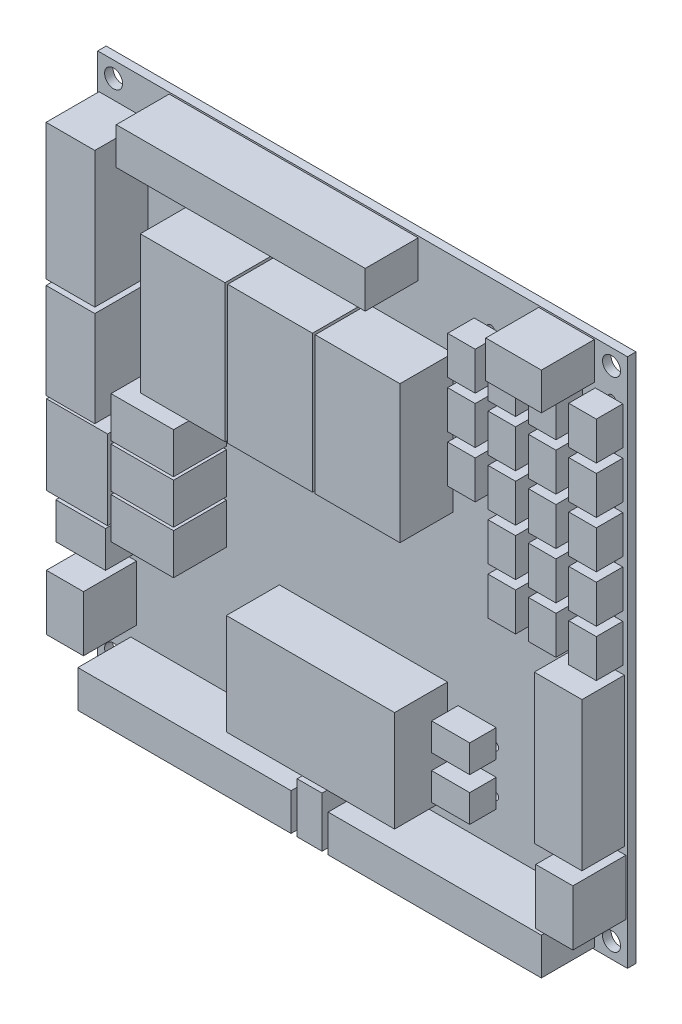
from build123d import *

# Parameters (mm, degrees)
ESQUISSE1_W        = 100.0000032
ESQUISSE1_H        = 100.0000032
ESQUISSE1_R        = 1.6999966
ESQUISSE1_R_2      = 1.1999976
ESQUISSE1_R_3      = 0.7500112
ESQUISSE1_R_4      = 0.4500118
BOSS_EXTRU_1_DEPTH = 1.6
ESQUISSE3_W        = 9.200007
ESQUISSE3_H        = 25.6200148
ESQUISSE3_H_2      = 18.0000148
ESQUISSE3_W_2      = 11.5000024
ESQUISSE3_H_3      = 14.9999954
ESQUISSE3_W_3      = 16.0000188
ESQUISSE3_H_4      = 25.9999988
ESQUISSE3_W_4      = 31.75
ESQUISSE3_H_5      = 19.05
ESQUISSE3_W_5      = 11.7999764
ESQUISSE3_H_6      = 7.6999846
BOSS_EXTRU_2_DEPTH = 10
ESQUISSE4_W        = 47.0000076
ESQUISSE4_H        = 6.999986
ESQUISSE4_W_2      = 10.5000044
ESQUISSE4_W_3      = 40.2500084
ESQUISSE4_W_4      = 6.999986
ESQUISSE4_H_2      = 10.5000044
ESQUISSE4_W_5      = 4.700016
ESQUISSE4_H_3      = 9.5000064
BOSS_EXTRU_3_DEPTH = 10
ESQUISSE5_W        = 5.1999896
ESQUISSE5_H        = 7.1999856
ESQUISSE5_W_2      = 7.1999856
ESQUISSE5_H_2      = 5.1999896
BOSS_EXTRU_4_DEPTH = 5
ESQUISSE6_W        = 9.3962982
ESQUISSE6_H        = 6.8525136
ESQUISSE6_W_2      = 8.999982
ESQUISSE6_H_2      = 27.9999948
BOSS_EXTRU_5_DEPTH = 8


with BuildPart() as part:
    # Esquisse1 → Boss.-Extru.1 (new body)
    with BuildSketch(Plane.XY):
        with Locations((50.0508016, 50.0508016)):
            Rectangle(ESQUISSE1_W, ESQUISSE1_H)
        with Locations((3.050794, 97.0508092)):
            Circle(ESQUISSE1_R, mode=Mode.SUBTRACT)
        with Locations((97.0508092, 97.0508092)):
            Circle(ESQUISSE1_R, mode=Mode.SUBTRACT)
        with Locations((97.0508092, 3.050794)):
            Circle(ESQUISSE1_R, mode=Mode.SUBTRACT)
        with Locations((3.050794, 3.050794)):
            Circle(ESQUISSE1_R, mode=Mode.SUBTRACT)
        with Locations((7.4058018, 64.0407914)):
            Circle(ESQUISSE1_R_2, mode=Mode.SUBTRACT)
        with Locations((7.4058018, 51.6308086)):
            Circle(ESQUISSE1_R_2, mode=Mode.SUBTRACT)
        with Locations((74.9837972, 23.9048036)):
            Circle(ESQUISSE1_R_3, mode=Mode.SUBTRACT)
        with Locations((74.9837972, 15.7768036)):
            Circle(ESQUISSE1_R_3, mode=Mode.SUBTRACT)
        with Locations((81.8607964, 91.6207972)):
            Circle(ESQUISSE1_R_3, mode=Mode.SUBTRACT)
        with Locations((81.8607964, 82.7307972)):
            Circle(ESQUISSE1_R_3, mode=Mode.SUBTRACT)
        with Locations((81.8607964, 73.8407972)):
            Circle(ESQUISSE1_R_3, mode=Mode.SUBTRACT)
        with Locations((81.8607964, 64.9507972)):
            Circle(ESQUISSE1_R_3, mode=Mode.SUBTRACT)
        with Locations((81.8607964, 56.0607972)):
            Circle(ESQUISSE1_R_3, mode=Mode.SUBTRACT)
        with Locations((74.2407964, 91.6207972)):
            Circle(ESQUISSE1_R_3, mode=Mode.SUBTRACT)
        with Locations((74.2407964, 82.7307972)):
            Circle(ESQUISSE1_R_3, mode=Mode.SUBTRACT)
        with Locations((74.2407964, 73.8407972)):
            Circle(ESQUISSE1_R_3, mode=Mode.SUBTRACT)
        with Locations((97.1007964, 91.6207972)):
            Circle(ESQUISSE1_R_3, mode=Mode.SUBTRACT)
        with Locations((97.1007964, 82.7307972)):
            Circle(ESQUISSE1_R_3, mode=Mode.SUBTRACT)
        with Locations((97.1007964, 73.8407972)):
            Circle(ESQUISSE1_R_3, mode=Mode.SUBTRACT)
        with Locations((97.1007964, 64.9507972)):
            Circle(ESQUISSE1_R_3, mode=Mode.SUBTRACT)
        with Locations((97.1007964, 56.0607972)):
            Circle(ESQUISSE1_R_3, mode=Mode.SUBTRACT)
        with Locations((89.4807964, 91.6207972)):
            Circle(ESQUISSE1_R_3, mode=Mode.SUBTRACT)
        with Locations((89.4807964, 82.7307972)):
            Circle(ESQUISSE1_R_3, mode=Mode.SUBTRACT)
        with Locations((89.4807964, 73.8407972)):
            Circle(ESQUISSE1_R_3, mode=Mode.SUBTRACT)
        with Locations((89.4807964, 64.9507972)):
            Circle(ESQUISSE1_R_3, mode=Mode.SUBTRACT)
        with Locations((89.4807964, 56.0607972)):
            Circle(ESQUISSE1_R_3, mode=Mode.SUBTRACT)
        with Locations((7.4058018, 90.7107914)):
            Circle(ESQUISSE1_R_2, mode=Mode.SUBTRACT)
        with Locations((7.4058018, 70.6808086)):
            Circle(ESQUISSE1_R_2, mode=Mode.SUBTRACT)
        with Locations((6.0527946, 29.0658042)):
            Circle(ESQUISSE1_R_4, mode=Mode.SUBTRACT)
        with Locations((6.0527946, 24.6657876)):
            Circle(ESQUISSE1_R_4, mode=Mode.SUBTRACT)
    extrude(amount=BOSS_EXTRU_1_DEPTH)

    # Esquisse3 → Boss.-Extru.2 (add)
    with BuildSketch(Plane.XY.offset(1.6)):
        with Locations((4.9057941, 80.6958)):
            Rectangle(ESQUISSE3_W, ESQUISSE3_H)
        with Locations((4.9057941, 57.8358)):
            Rectangle(ESQUISSE3_W, ESQUISSE3_H_2)
        with Locations((6.1557916, 40.8508073)):
            Rectangle(ESQUISSE3_W_2, ESQUISSE3_H_3)
        with Locations((26.0858, 71.1708)):
            Rectangle(ESQUISSE3_W_3, ESQUISSE3_H_4)
        with Locations((42.5958, 71.1708)):
            Rectangle(ESQUISSE3_W_3, ESQUISSE3_H_4)
        with Locations((59.1058, 71.1708)):
            Rectangle(ESQUISSE3_W_3, ESQUISSE3_H_4)
        with Locations((50.2158, 20.3708)):
            Rectangle(ESQUISSE3_W_4, ESQUISSE3_H_5)
        with Locations((18.4658, 51.4307963)):
            Rectangle(ESQUISSE3_W_5, ESQUISSE3_H_6)
        with Locations((18.4658, 43.1757963)):
            Rectangle(ESQUISSE3_W_5, ESQUISSE3_H_6)
        with Locations((18.4658, 34.9207963)):
            Rectangle(ESQUISSE3_W_5, ESQUISSE3_H_6)
    extrude(amount=BOSS_EXTRU_2_DEPTH)

    # Esquisse4 → Boss.-Extru.3 (add)
    with BuildSketch(Plane.XY.offset(1.6)):
        with Locations((37.0508022, 96.2408032)):
            Rectangle(ESQUISSE4_W, ESQUISSE4_H)
        with Locations((88.5508008, 96.2408032)):
            Rectangle(ESQUISSE4_W_2, ESQUISSE4_H)
        with Locations((26.4258044, 3.8608)):
            Rectangle(ESQUISSE4_W_3, ESQUISSE4_H)
        with Locations((73.6757988, 3.8608)):
            Rectangle(ESQUISSE4_W_3, ESQUISSE4_H)
        with Locations((96.2408032, 13.1457954)):
            Rectangle(ESQUISSE4_W_4, ESQUISSE4_H_2)
        with Locations((3.8608, 15.0507954)):
            Rectangle(ESQUISSE4_W_4, ESQUISSE4_H_2)
        with Locations((50.0508016, 5.1308)):
            Rectangle(ESQUISSE4_W_5, ESQUISSE4_H_3)
    extrude(amount=BOSS_EXTRU_3_DEPTH)

    # Esquisse5 → Boss.-Extru.4 (add)
    with BuildSketch(Plane.XY.offset(1.6)):
        with Locations((73.7108, 88.3158)):
            Rectangle(ESQUISSE5_W, ESQUISSE5_H)
        with Locations((81.3308, 88.3158)):
            Rectangle(ESQUISSE5_W, ESQUISSE5_H)
        with Locations((88.9508, 88.3158)):
            Rectangle(ESQUISSE5_W, ESQUISSE5_H)
        with Locations((96.5708, 88.3158)):
            Rectangle(ESQUISSE5_W, ESQUISSE5_H)
        with Locations((96.5708, 79.4258)):
            Rectangle(ESQUISSE5_W, ESQUISSE5_H)
        with Locations((88.9508, 79.4258)):
            Rectangle(ESQUISSE5_W, ESQUISSE5_H)
        with Locations((81.3308, 79.4258)):
            Rectangle(ESQUISSE5_W, ESQUISSE5_H)
        with Locations((73.7108, 79.4258)):
            Rectangle(ESQUISSE5_W, ESQUISSE5_H)
        with Locations((73.7108, 70.5358)):
            Rectangle(ESQUISSE5_W, ESQUISSE5_H)
        with Locations((81.3308, 70.5358)):
            Rectangle(ESQUISSE5_W, ESQUISSE5_H)
        with Locations((88.9508, 70.5358)):
            Rectangle(ESQUISSE5_W, ESQUISSE5_H)
        with Locations((96.5708, 70.5358)):
            Rectangle(ESQUISSE5_W, ESQUISSE5_H)
        with Locations((96.5708, 61.6458)):
            Rectangle(ESQUISSE5_W, ESQUISSE5_H)
        with Locations((88.9508, 61.6458)):
            Rectangle(ESQUISSE5_W, ESQUISSE5_H)
        with Locations((81.3308, 61.6458)):
            Rectangle(ESQUISSE5_W, ESQUISSE5_H)
        with Locations((81.3308, 52.7558)):
            Rectangle(ESQUISSE5_W, ESQUISSE5_H)
        with Locations((88.9508, 52.7558)):
            Rectangle(ESQUISSE5_W, ESQUISSE5_H)
        with Locations((96.5708, 52.7558)):
            Rectangle(ESQUISSE5_W, ESQUISSE5_H)
        with Locations((71.6788, 16.3068)):
            Rectangle(ESQUISSE5_W_2, ESQUISSE5_H_2)
        with Locations((71.6788, 24.4348)):
            Rectangle(ESQUISSE5_W_2, ESQUISSE5_H_2)
    extrude(amount=BOSS_EXTRU_4_DEPTH)

    # Esquisse6 → Boss.-Extru.5 (add)
    with BuildSketch(Plane.XY.offset(1.6)):
        with Locations((4.8327437, 27.2811494)):
            Rectangle(ESQUISSE6_W, ESQUISSE6_H)
        with Locations((94.9657994, 33.7058)):
            Rectangle(ESQUISSE6_W_2, ESQUISSE6_H_2)
    extrude(amount=BOSS_EXTRU_5_DEPTH)


solid = part.part
